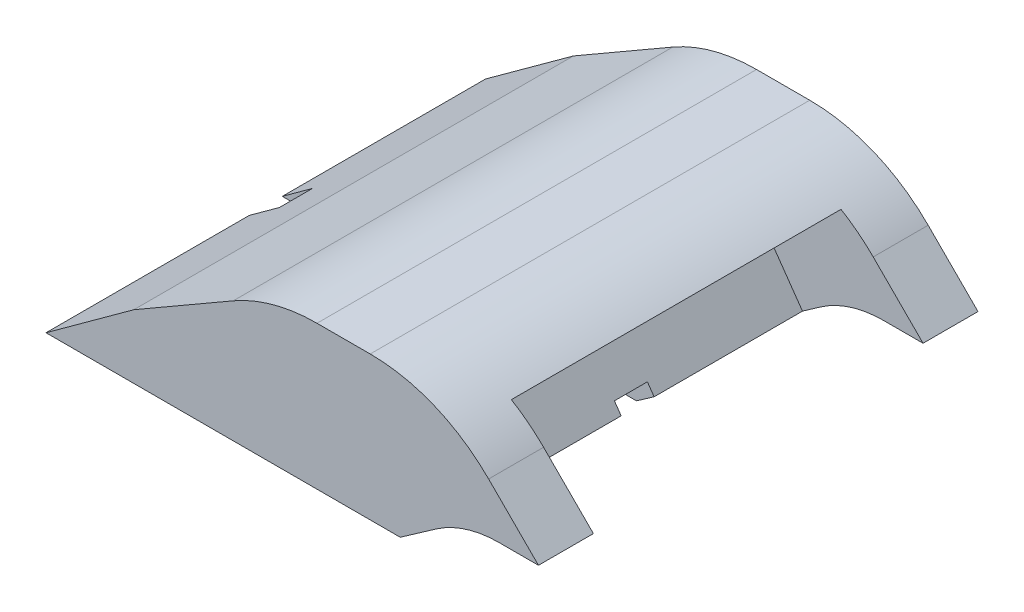
from build123d import *

# Parameters (mm, degrees)
BOSS_EXTRUDE1_DEPTH     = 20
FILLET1_R               = 7.62
SKETCH2_W               = 14.64163524
SKETCH2_H               = 15
CUT_EXTRUDE3_DEPTH      = 4.607313514
CUT_EXTRUDE3_DEPTH_BACK = 3
SKETCH3_W               = 1.5
SKETCH3_H               = 1
CUT_EXTRUDE4_DEPTH      = 22.118365096


with BuildPart() as part:
    # Sketch1 → Boss-Extrude1 (new body)
    with BuildSketch(Plane.XY):
        with BuildLine():
            Line((-21.118365096, 5.5), (-17.118365096, 8.408769901))
            Line((-17.118365096, 8.408769901), (-10.829358836, 12.039729358))
            Line((-10.829358836, 12.039729358), (-3.209358836, 12.039729358))
            Line((-3.209358836, 12.039729358), (1.290641164, 7.539729358))
            Line((1.290641164, 7.539729358), (-0.508988662, 7.539729358))
            ThreePointArc((-0.508988662, 7.539729358), (-2.01251766, 7.308314112), (-3.376870844, 6.635489579))
            Line((-3.376870844, 6.635489579), (-4.998518024, 5.5))
            Line((-4.998518024, 5.5), (-21.118365096, 5.5))
        make_face()
    extrude(amount=-BOSS_EXTRUDE1_DEPTH)

    # Fillet1
    fillet1_edges = [part.edges().sort_by_distance(p)[0] for p in [
        (-3.209358836, 12.039729358, -10),
        (-10.829358836, 12.039729358, -10),
    ]]
    fillet(fillet1_edges, radius=FILLET1_R)

    # Sketch2 → Cut-Extrude3 (cut, two sides)
    with BuildSketch(Plane(origin=(-4.228616794, 6.039090645, 0), x_dir=(0.819152044, 0.573576436, 0), z_dir=(0.573576436, -0.819152044, 0))) as cut_extrude3_sk:
        with Locations((7.360607431, -10)):
            Rectangle(SKETCH2_W, SKETCH2_H)
    extrude(amount=CUT_EXTRUDE3_DEPTH, mode=Mode.SUBTRACT)
    extrude(cut_extrude3_sk.sketch, amount=-CUT_EXTRUDE3_DEPTH_BACK, mode=Mode.SUBTRACT)

    # Sketch3 → Cut-Extrude4 (cut, through all)
    with BuildSketch(Plane(origin=(0, 0, 0), x_dir=(0, 0, -1), z_dir=(1, 0, 0))):
        with Locations((10, 6)):
            Rectangle(SKETCH3_W, SKETCH3_H)
    extrude(amount=-CUT_EXTRUDE4_DEPTH, mode=Mode.SUBTRACT)


solid = part.part
